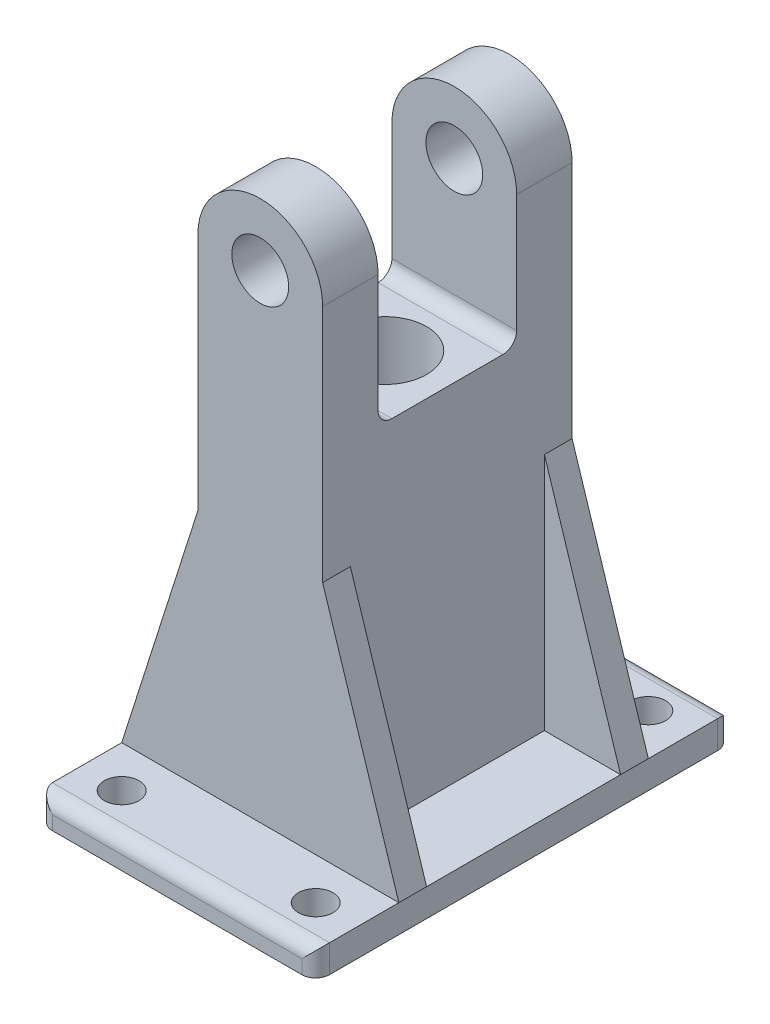
from build123d import *

# Parameters (mm, degrees)
SKETCH_1_R           = 4.1
EXTRUDE_1_DEPTH      = 18
EXTRUDE_1_DEPTH_BACK = 18
SKETCH_3_W           = 40
SKETCH_3_H           = 60
EXTRUDE_2_DEPTH      = 4
CUT_EXTRUDE_START    = 50
SKETCH_4_W           = 18
SKETCH_4_H           = 20
CUT_EXTRUDE_1_DEPTH  = 29
SKETCH_5_R           = 6
CUT_EXTRUDE_2_DEPTH  = 55
EXTRUDE_START        = 18
EXTRUDE_3_DEPTH      = 4
EXTRUDE_START_2      = -18
EXTRUDE_4_DEPTH      = 4
SKETCH_7_R           = 2.5
CUT_EXTRUDE_4_DEPTH  = 5
FILLET_1_R           = 2


with BuildPart() as part:
    # Sketch 1 → Extrude 1 (new body, two sides)
    with BuildSketch(Plane.XY) as extrude_1_sk:
        with BuildLine():
            Line((-9, 0), (-9, -73))
            Line((-9, -73), (9, -73))
            Line((9, -73), (9, 0))
            ThreePointArc((9, 0), (0, 9), (-9, 0))
        make_face()
        Circle(SKETCH_1_R, mode=Mode.SUBTRACT)
    extrude(amount=EXTRUDE_1_DEPTH)
    extrude(extrude_1_sk.sketch, amount=-EXTRUDE_1_DEPTH_BACK)

    # Sketch 3 → Extrude 2 (add)
    with BuildSketch(Plane.XZ.offset(73)):
        Rectangle(SKETCH_3_W, SKETCH_3_H)
    extrude(amount=-EXTRUDE_2_DEPTH)

    # Sketch 4 → Cut-Extrude 1 (cut, through all)
    with BuildSketch(Plane(origin=(0, -69, 0), x_dir=(1, 0, 0), z_dir=(0, 1, 0)).offset(CUT_EXTRUDE_START)):
        Rectangle(SKETCH_4_W, SKETCH_4_H)
    extrude(amount=CUT_EXTRUDE_1_DEPTH, mode=Mode.SUBTRACT)

    # Sketch 5 → Cut-Extrude 2 (cut, through all)
    with BuildSketch(Plane(origin=(0, -19, 0), x_dir=(1, 0, 0), z_dir=(0, 1, 0))):
        Circle(SKETCH_5_R)
    extrude(amount=-CUT_EXTRUDE_2_DEPTH, mode=Mode.SUBTRACT)

    # Sketch 6 → Extrude 3 (add)
    with BuildSketch(Plane.XY.offset(EXTRUDE_START)):
        Polygon((-20, -69), (-9, -34.5), (-9, -69), align=None)
        Polygon((9, -34.5), (20, -69), (9, -69), align=None)
    extrude(amount=-EXTRUDE_3_DEPTH)

    # Sketch 6_3 → Extrude 4 (add)
    with BuildSketch(Plane.XY.offset(EXTRUDE_START_2)):
        Polygon((-20, -69), (-9, -34.5), (-9, -69), align=None)
        Polygon((9, -34.5), (20, -69), (9, -69), align=None)
    extrude(amount=EXTRUDE_4_DEPTH)

    # Sketch 7 → Cut-Extrude 4 (cut, through all)
    with BuildSketch(Plane(origin=(0, -69, 0), x_dir=(1, 0, 0), z_dir=(0, 1, 0))):
        with Locations((-14, -24)):
            Circle(SKETCH_7_R)
        with Locations((-14, 24)):
            Circle(SKETCH_7_R)
        with Locations((14, 24)):
            Circle(SKETCH_7_R)
        with Locations((14, -24)):
            Circle(SKETCH_7_R)
    extrude(amount=-CUT_EXTRUDE_4_DEPTH, mode=Mode.SUBTRACT)

    # Fillet 1
    fillet_1_edges = [part.edges().sort_by_distance(p)[0] for p in [
        (-20, -71, -30),
        (0, -69, 30),
        (-20, -71, 30),
        (20, -71, 30),
        (0, -69, -30),
        (20, -71, -30),
        (0, -19, -10),
        (0, -19, 10),
    ]]
    fillet(fillet_1_edges, radius=FILLET_1_R)


solid = part.part
